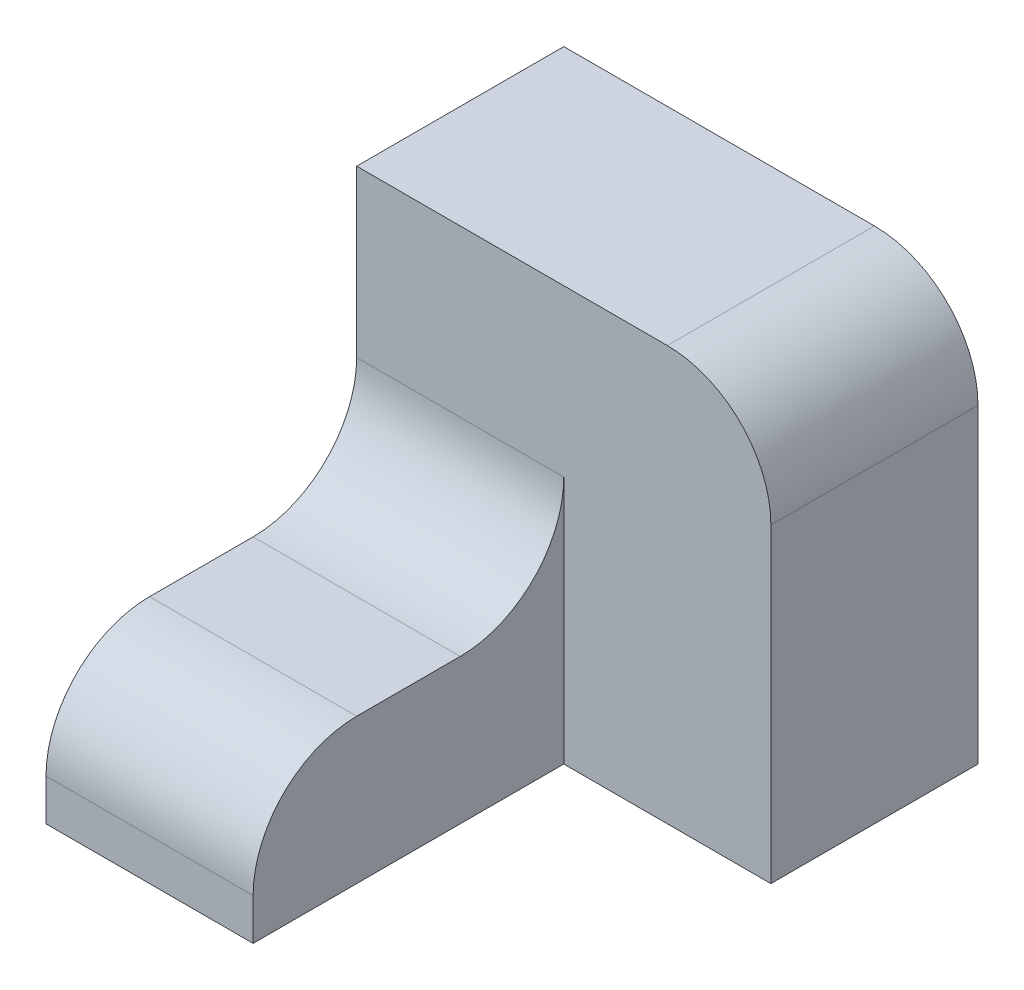
from build123d import *

# Parameters (mm, degrees)
SKETCH1_W           = 20
SKETCH1_H           = 14
BOSS_EXTRUDE1_DEPTH = 30
SKETCH2_W           = 40
SKETCH2_H           = 40
BOSS_EXTRUDE2_DEPTH = 20
FILLET1_R           = 10


with BuildPart() as part:
    # Sketch1 → Boss-Extrude1 (new body)
    with BuildSketch(Plane.XY):
        with Locations((-20, -7)):
            Rectangle(SKETCH1_W, SKETCH1_H)
    extrude(amount=BOSS_EXTRUDE1_DEPTH)

    # Sketch2 → Boss-Extrude2 (add)
    with BuildSketch(Plane.XY):
        with Locations((-10, 6)):
            Rectangle(SKETCH2_W, SKETCH2_H)
    extrude(amount=-BOSS_EXTRUDE2_DEPTH)

    # Fillet1
    fillet1_edges = [part.edges().sort_by_distance(p)[0] for p in [
        (10, 26, -10),
        (-20, 0, 30),
        (-20, 0, 0),
    ]]
    fillet(fillet1_edges, radius=FILLET1_R)


solid = part.part
